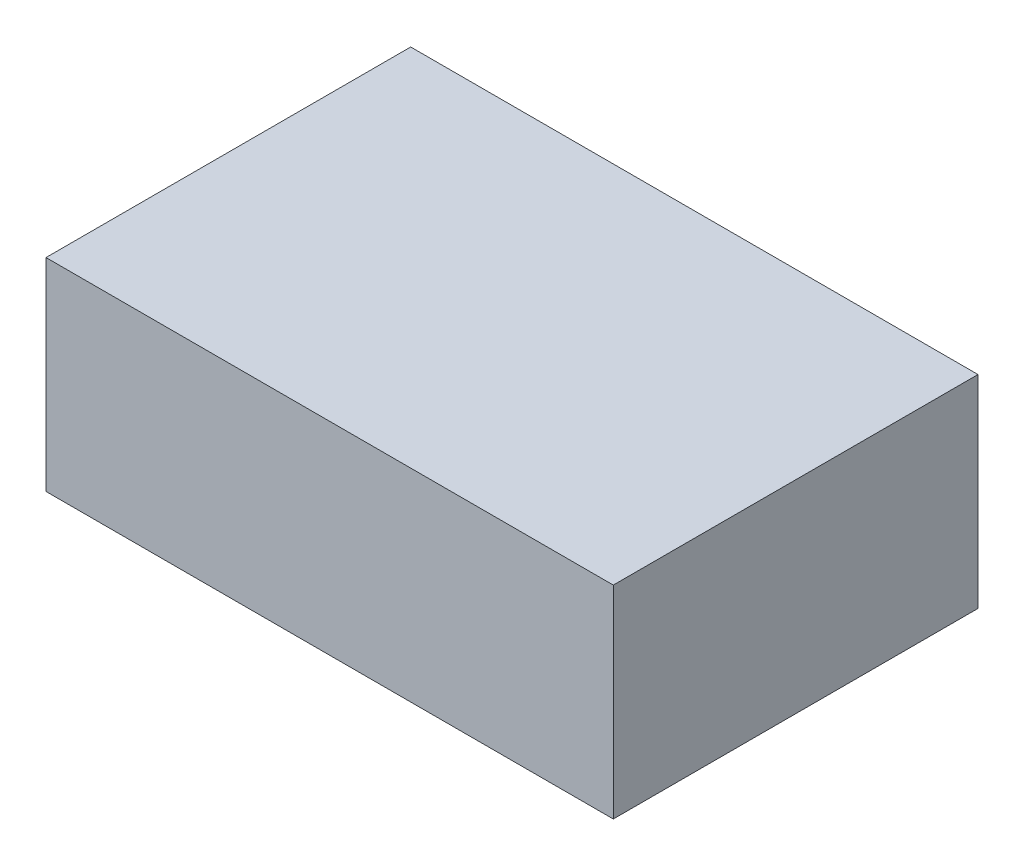
from build123d import *

# Parameters (mm, degrees)
SKETCH1_W           = 14
SKETCH1_H           = 9
BOSS_EXTRUDE1_DEPTH = 5


with BuildPart() as part:
    # Sketch1 → Boss-Extrude1 (new body)
    with BuildSketch(Plane(origin=(0, 0, 0), x_dir=(1, 0, 0), z_dir=(0, 1, 0))):
        Rectangle(SKETCH1_W, SKETCH1_H)
    extrude(amount=BOSS_EXTRUDE1_DEPTH)


solid = part.part
